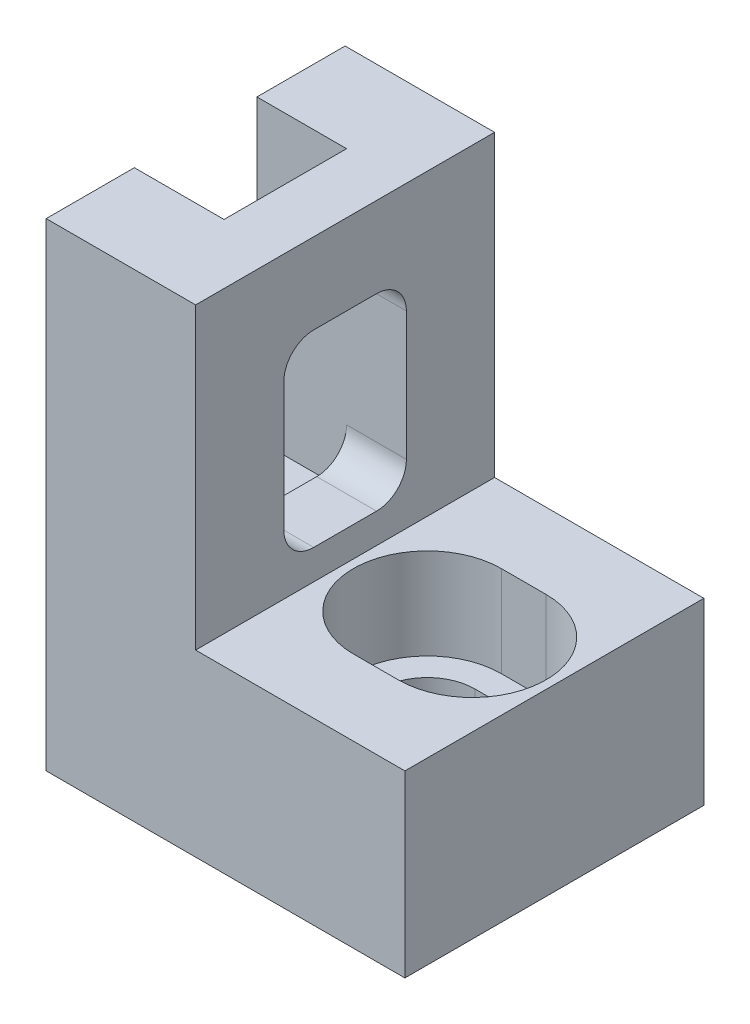
from build123d import *

# Parameters (mm, degrees)
SKETCH1_W           = 10
SKETCH1_H           = 16
BOSS_EXTRUDE1_DEPTH = 12
SKETCH2_W           = 7
SKETCH2_H           = 10
CUT_EXTRUDE1_DEPTH  = 19.01714389
CUT_EXTRUDE2_DEPTH  = 17.615986871
CUT_EXTRUDE3_DEPTH  = 3.0448
SKETCH4_W           = 4.1
SKETCH4_H           = 6.3
CUT_EXTRUDE4_DEPTH  = 17.022125129
FILLET2_R           = 1
SKETCH4_6_W         = 4.1
SKETCH4_6_H         = 9.924876291
CUT_EXTRUDE7_DEPTH  = 3


with BuildPart() as part:
    # Sketch1 → Boss-Extrude1 (new body)
    with BuildSketch(Plane(origin=(0, 0, 0), x_dir=(0, 0, -1), z_dir=(1, 0, 0))):
        with Locations((0.664893617, 0.978723404)):
            Rectangle(SKETCH1_W, SKETCH1_H)
    extrude(amount=BOSS_EXTRUDE1_DEPTH)

    # Sketch2 → Cut-Extrude1 (cut, through all)
    with BuildSketch(Plane.XY.offset(4.335106383)):
        with Locations((8.5, 3.978723404)):
            Rectangle(SKETCH2_W, SKETCH2_H)
    extrude(amount=-CUT_EXTRUDE1_DEPTH, mode=Mode.SUBTRACT)

    # Sketch3 → Cut-Extrude2 (cut, through all)
    with BuildSketch(Plane(origin=(0, -1.021276596, 0), x_dir=(1, 0, 0), z_dir=(0, 1, 0))):
        with BuildLine():
            ThreePointArc((7.75, 2.254893617), (6.16, 0.664893617), (7.75, -0.925106383))
            Line((7.75, -0.925106383), (9.25, -0.925106383))
            ThreePointArc((9.25, -0.925106383), (10.84, 0.664893617), (9.25, 2.254893617))
            Line((9.25, 2.254893617), (7.75, 2.254893617))
        make_face()
    extrude(amount=-CUT_EXTRUDE2_DEPTH, mode=Mode.SUBTRACT)

    # Sketch3_3 → Cut-Extrude3 (cut)
    with BuildSketch(Plane(origin=(0, -1.021276596, 0), x_dir=(1, 0, 0), z_dir=(0, 1, 0))):
        with BuildLine():
            ThreePointArc((7.75, 3.138993617), (5.2759, 0.664893617), (7.75, -1.809206383))
            Line((7.75, -1.809206383), (9.25, -1.809206383))
            ThreePointArc((9.25, -1.809206383), (11.7241, 0.664893617), (9.25, 3.138993617))
            Line((9.25, 3.138993617), (7.75, 3.138993617))
        make_face()
        with BuildLine():
            ThreePointArc((9.25, 2.254893617), (10.84, 0.664893617), (9.25, -0.925106383))
            Line((9.25, -0.925106383), (7.75, -0.925106383))
            ThreePointArc((7.75, -0.925106383), (6.16, 0.664893617), (7.75, 2.254893617))
            Line((7.75, 2.254893617), (9.25, 2.254893617))
        make_face(mode=Mode.SUBTRACT)
    extrude(amount=-CUT_EXTRUDE3_DEPTH, mode=Mode.SUBTRACT)

    # Sketch4 → Cut-Extrude4 (cut, through all)
    with BuildSketch(Plane.ZY):
        with Locations((-0.664893617, 3.128723404)):
            Rectangle(SKETCH4_W, SKETCH4_H)
    extrude(amount=-CUT_EXTRUDE4_DEPTH, mode=Mode.SUBTRACT)

    # Fillet2
    fillet2_edges = [part.edges().sort_by_distance(p)[0] for p in [
        (2.5, -0.021276596, 1.385106383),
        (2.5, 6.278723404, 1.385106383),
        (2.5, 6.278723404, -2.714893617),
        (2.5, -0.021276596, -2.714893617),
    ]]
    fillet(fillet2_edges, radius=FILLET2_R)

    # Sketch4_6 → Cut-Extrude7 (cut)
    with BuildSketch(Plane.ZY):
        with Locations((-0.664893617, 4.016285258)):
            Rectangle(SKETCH4_6_W, SKETCH4_6_H)
    extrude(amount=-CUT_EXTRUDE7_DEPTH, mode=Mode.SUBTRACT)


solid = part.part
